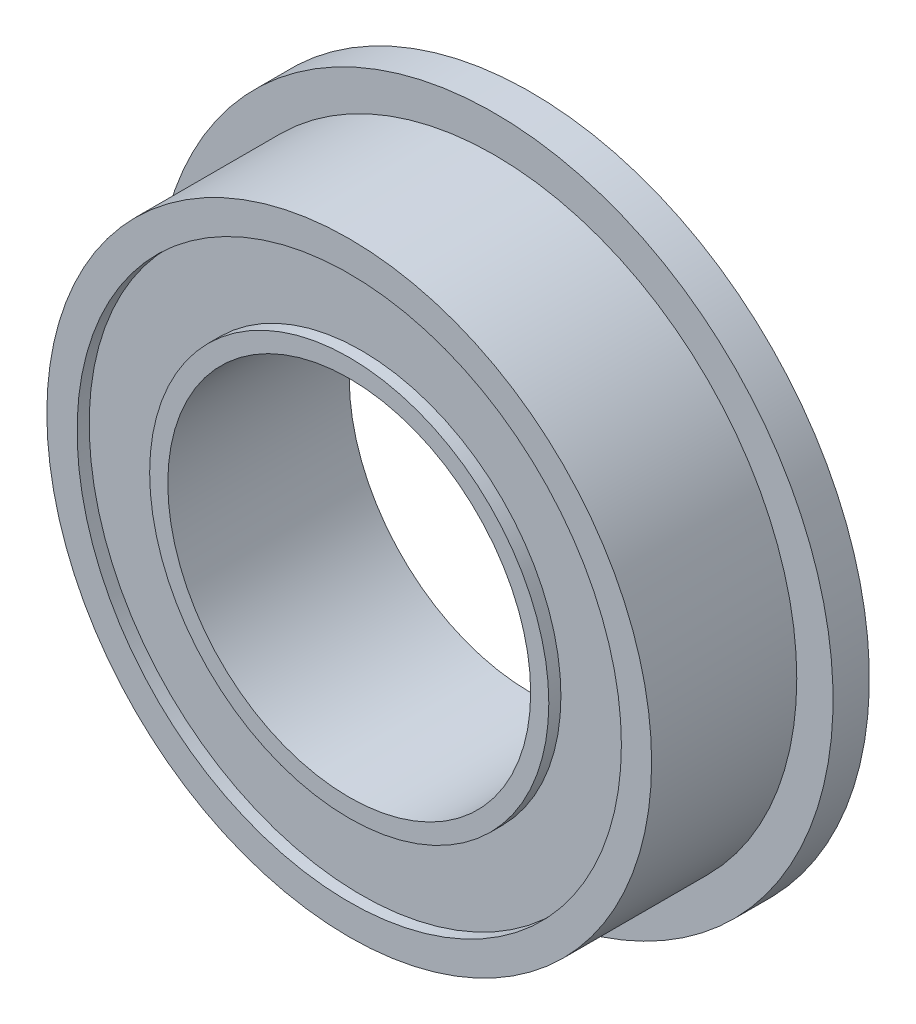
from build123d import *

# Parameters (mm, degrees)
SKETCH_1_R          = 5
EXTRUDE_1_DEPTH     = 1.5
SKETCH_4_R          = 5.6
EXTRUDE_2_DEPTH     = 0.6
SKETCH_2_R          = 3
CUT_EXTRUDE_1_DEPTH = 4
SKETCH_3_R          = 4.5
SKETCH_3_R_2        = 3.3
CUT_EXTRUDE_2_DEPTH = 0.2


with BuildPart() as part:
    # 草圖1 → 填料-伸長1 (new body, symmetric)
    with BuildSketch(Plane.XY):
        Circle(SKETCH_1_R)
    extrude(amount=EXTRUDE_1_DEPTH, both=True)

    # 草圖4 → 填料-伸長2 (add)
    with BuildSketch(Plane(origin=(0, 0, -1.5), x_dir=(-1, 0, 0), z_dir=(0, 0, -1))):
        Circle(SKETCH_4_R)
    extrude(amount=-EXTRUDE_2_DEPTH)

    # 草圖2 → 除料-伸長1 (cut, through all)
    with BuildSketch(Plane.XY.offset(1.5)):
        Circle(SKETCH_2_R)
    extrude(amount=-CUT_EXTRUDE_1_DEPTH, mode=Mode.SUBTRACT)

    # 草圖3 → 除料-伸長2 (cut)
    with BuildSketch(Plane.XY.offset(1.5)):
        Circle(SKETCH_3_R)
        Circle(SKETCH_3_R_2, mode=Mode.SUBTRACT)
    cut_extrude_2 = extrude(amount=-CUT_EXTRUDE_2_DEPTH, mode=Mode.SUBTRACT)

    # 鏡射1: 除料-伸長2 across plane
    add(cut_extrude_2.mirror(Plane.XY), mode=Mode.SUBTRACT)


solid = part.part
